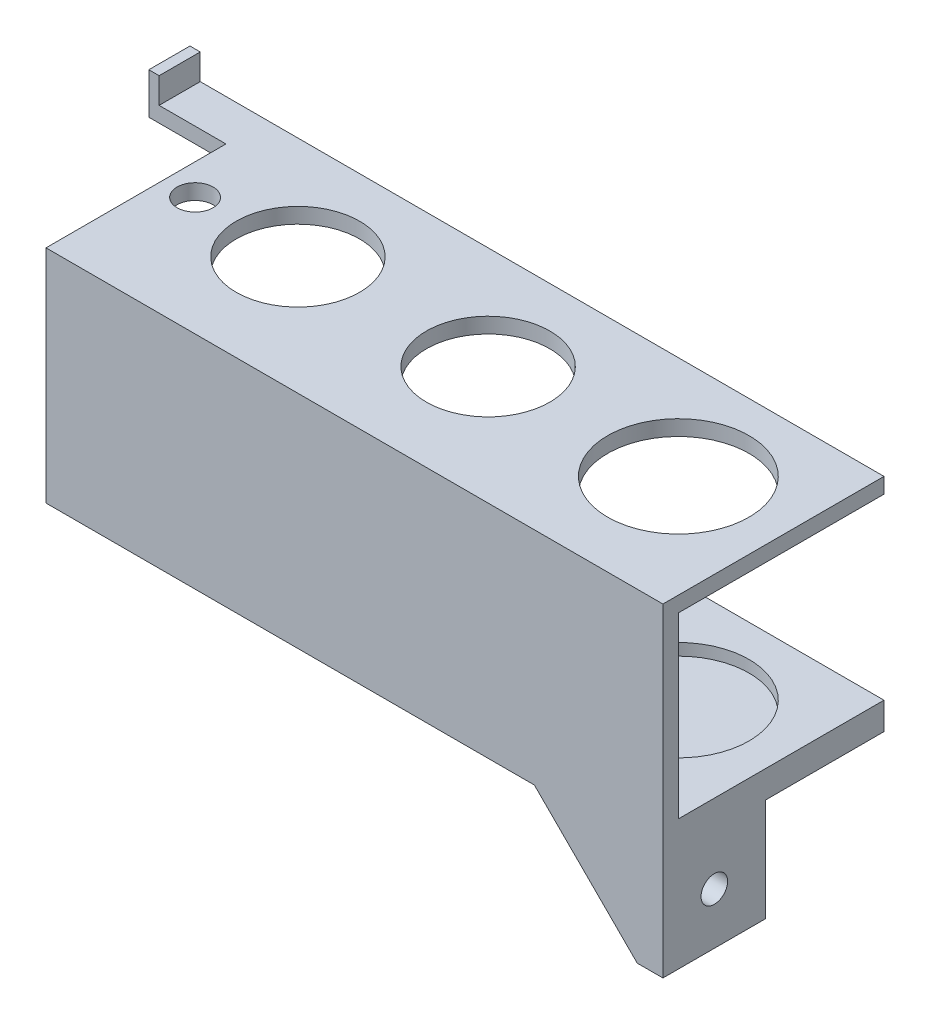
from build123d import *

# Parameters (mm, degrees)
SKETCH1_W           = 3
SKETCH1_H           = 40
BOSS_EXTRUDE1_DEPTH = 120
SKETCH9_W           = 120
SKETCH9_H           = 3
BOSS_EXTRUDE2_DEPTH = 40
SKETCH10_W          = 120
SKETCH10_H          = 40
SKETCH10_R          = 13.75
SKETCH10_R_2        = 7.6
SKETCH10_R_3        = 2.26
BOSS_EXTRUDE3_DEPTH = 2.3
SKETCH11_R          = 7
SKETCH11_R_2        = 2.25
SKETCH11_R_3        = 2.26
CUT_EXTRUDE5_DEPTH  = 4
SKETCH12_W          = 120
SKETCH12_H          = 43
SKETCH12_R          = 3.5
SKETCH12_R_2        = 12
SKETCH12_R_3        = 13.75
BOSS_EXTRUDE4_DEPTH = 3
SKETCH13_W          = 20
SKETCH13_H          = 20
SKETCH13_R          = 2.583718127
BOSS_EXTRUDE5_DEPTH = 5
BOSS_EXTRUDE6_DEPTH = 2
SKETCH15_W          = 15
SKETCH15_H          = 8
BOSS_EXTRUDE7_DEPTH = 3
SKETCH16_W          = 2
SKETCH16_H          = 8
BOSS_EXTRUDE8_DEPTH = 5


with BuildPart() as part:
    # Sketch1 → Boss-Extrude1 (new body)
    with BuildSketch(Plane(origin=(0, 0, 0), x_dir=(0, 0, -1), z_dir=(1, 0, 0))):
        with Locations((1.5, -13)):
            Rectangle(SKETCH1_W, SKETCH1_H)
    extrude(amount=BOSS_EXTRUDE1_DEPTH)

    # Sketch9 → Boss-Extrude2 (add)
    with BuildSketch(Plane(origin=(0, 0, -3), x_dir=(-1, 0, 0), z_dir=(0, 0, -1))):
        with Locations((-60, -31.5)):
            Rectangle(SKETCH9_W, SKETCH9_H)
    extrude(amount=BOSS_EXTRUDE2_DEPTH)

    # Sketch10 → Boss-Extrude3 (add)
    with BuildSketch(Plane(origin=(0, -30, 0), x_dir=(1, 0, 0), z_dir=(0, 1, 0))):
        with Locations((60, 23)):
            Rectangle(SKETCH10_W, SKETCH10_H)
        with Locations((100, 23)):
            Circle(SKETCH10_R, mode=Mode.SUBTRACT)
        with Locations((63, 23)):
            Circle(SKETCH10_R_2, mode=Mode.SUBTRACT)
        with Locations((26, 23)):
            Circle(SKETCH10_R_2, mode=Mode.SUBTRACT)
        with Locations((6, 23)):
            Circle(SKETCH10_R_3, mode=Mode.SUBTRACT)
    extrude(amount=BOSS_EXTRUDE3_DEPTH)

    # Sketch11 → Cut-Extrude5 (cut, through all)
    with BuildSketch(Plane(origin=(0, -30, 0), x_dir=(1, 0, 0), z_dir=(0, 1, 0))):
        with Locations((63, 23)):
            Circle(SKETCH11_R)
        with Locations((26, 23)):
            Circle(SKETCH11_R_2)
        with Locations((6, 23)):
            Circle(SKETCH11_R_3)
    extrude(amount=-CUT_EXTRUDE5_DEPTH, mode=Mode.SUBTRACT)

    # Sketch12 → Boss-Extrude4 (add)
    with BuildSketch(Plane(origin=(0, 7, 0), x_dir=(1, 0, 0), z_dir=(0, 1, 0))):
        with Locations((60, 21.5)):
            Rectangle(SKETCH12_W, SKETCH12_H)
        with Locations((6, 23)):
            Circle(SKETCH12_R, mode=Mode.SUBTRACT)
        with Locations((26, 23)):
            Circle(SKETCH12_R_2, mode=Mode.SUBTRACT)
        with Locations((63, 23)):
            Circle(SKETCH12_R_2, mode=Mode.SUBTRACT)
        with Locations((100, 23)):
            Circle(SKETCH12_R_3, mode=Mode.SUBTRACT)
    extrude(amount=BOSS_EXTRUDE4_DEPTH)

    # Sketch13 → Boss-Extrude5 (add)
    with BuildSketch(Plane(origin=(120, 0, 0), x_dir=(0, 0, -1), z_dir=(1, 0, 0))):
        with Locations((10, -43)):
            Rectangle(SKETCH13_W, SKETCH13_H)
        with Locations((10, -43)):
            Circle(SKETCH13_R, mode=Mode.SUBTRACT)
    extrude(amount=-BOSS_EXTRUDE5_DEPTH)

    # Sketch14 → Boss-Extrude6 (add)
    with BuildSketch(Plane.XY):
        Polygon((115, -53), (115, -33), (95, -33), align=None)
    extrude(amount=-BOSS_EXTRUDE6_DEPTH)

    # Sketch15 → Boss-Extrude7 (add)
    with BuildSketch(Plane(origin=(0, 10, 0), x_dir=(1, 0, 0), z_dir=(0, 1, 0))):
        with Locations((-7.5, 39)):
            Rectangle(SKETCH15_W, SKETCH15_H)
    extrude(amount=-BOSS_EXTRUDE7_DEPTH)

    # Sketch16 → Boss-Extrude8 (add)
    with BuildSketch(Plane(origin=(0, 10, 0), x_dir=(1, 0, 0), z_dir=(0, 1, 0))):
        with Locations((-14, 39)):
            Rectangle(SKETCH16_W, SKETCH16_H)
    extrude(amount=BOSS_EXTRUDE8_DEPTH)


solid = part.part
